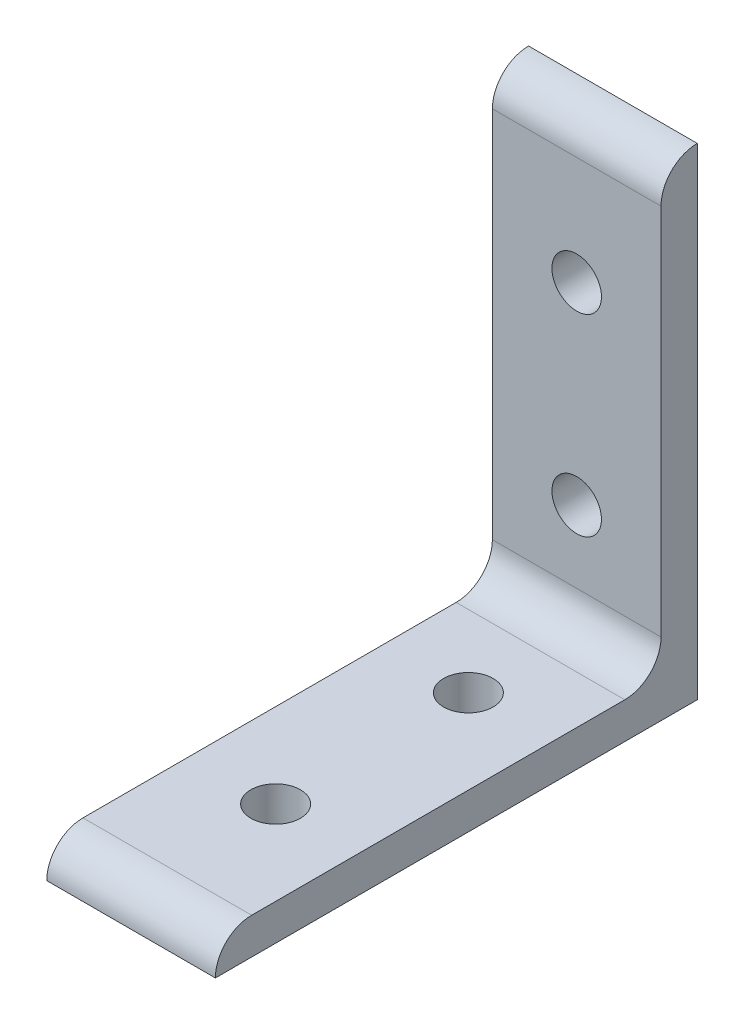
from build123d import *

# Parameters (mm, degrees)
EXTRUDE1_DEPTH     = 22.225
SKETCH2_R          = 3.2639
CUT_EXTRUDE1_DEPTH = 22.225
FILLET1_R          = 4.7752


with BuildPart() as part:
    # Sketch1 → Extrude1 (new body)
    with BuildSketch(Plane(origin=(0, 0, 0), x_dir=(0, 0, -1), z_dir=(1, 0, 0))):
        with BuildLine():
            Line((23.97075862, -29.606090317), (19.19555862, -24.830890317))
            Line((19.19555862, -24.830890317), (-34.75404138, -24.830890317))
            ThreePointArc((-34.75404138, -24.830890317), (-38.130617682, -26.229514015), (-39.52924138, -29.606090317))
            Line((-39.52924138, -29.606090317), (23.97075862, -29.606090317))
        make_face()
    extrude(amount=EXTRUDE1_DEPTH)

    # Sketch2 → Cut-Extrude1 (cut)
    with BuildSketch(Plane(origin=(0, -24.830890317, 0), x_dir=(1, 0, 0), z_dir=(0, 1, 0))):
        with Locations(Location((11.1125, -20.47924138, 0), (0, 0, 270))):  # turned: the seam where the file's is
            Circle(SKETCH2_R)
        with Locations(Location((11.1125, 4.92075862, 0), (0, 0, 270))):  # turned: the seam where the file's is
            Circle(SKETCH2_R)
    extrude(amount=-CUT_EXTRUDE1_DEPTH, mode=Mode.SUBTRACT)

    # Mirror1: part across plane


with BuildPart() as part_1:
    add(part.part)
    add(part.part.mirror(Plane(origin=(22.225, -29.606090317, -23.97075862), x_dir=(0, 0.707106781, 0.707106781), z_dir=(0, -0.707106781, 0.707106781))))

    # Fillet1
    fillet1_edges = [part_1.edges().sort_by_distance(p)[0] for p in [
        (11.1125, -24.830890317, -19.19555862),
    ]]
    fillet(fillet1_edges, radius=FILLET1_R)


solid = part_1.part
